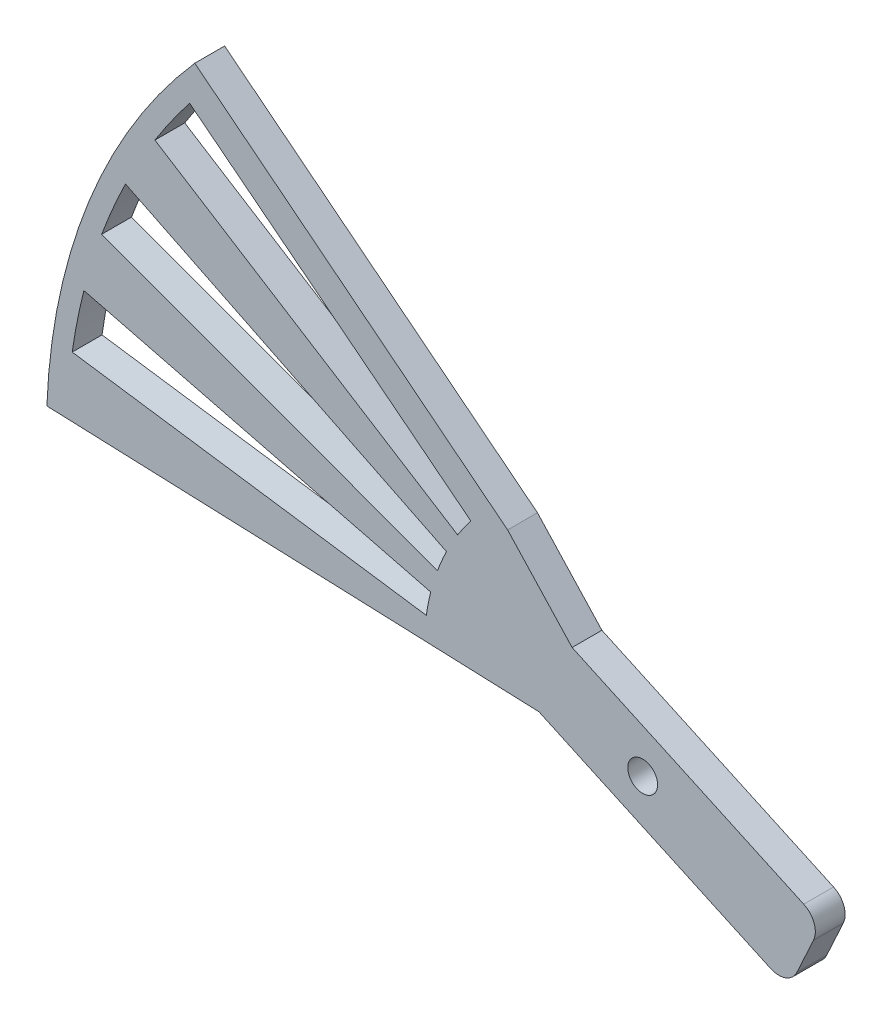
from build123d import *

# Parameters (mm, degrees)
BOSS_EXTRUDE2_DEPTH = 3
SKETCH1_8_R         = 1.5
BOSS_EXTRUDE5_DEPTH = 3
FILLET1_R           = 2
CUT_EXTRUDE1_REACH  = 73.918


with BuildPart() as part:
    # Sketch1 → Boss-Extrude2 (new body)
    with BuildSketch(Plane.XY):
        with BuildLine():
            Line((-19.985447982, 0.762803358), (-59.956343946, 2.288410074))
            ThreePointArc((-59.956343946, 2.288410074), (-55.730717245, 22.228071336), (-45.073672701, 39.602576043))
            Line((-45.073672701, 39.602576043), (-13.592462366, 14.67122922))
            ThreePointArc((-13.592462366, 14.67122922), (-18.172234131, 8.352838241), (-19.985447982, 0.762803358))
        make_face()
    extrude(amount=BOSS_EXTRUDE2_DEPTH)

    # Sketch1_8 → Boss-Extrude5 (add)
    with BuildSketch(Plane.XY):
        with BuildLine():
            ThreePointArc((-19.475648091, 4.549629811), (-19.821189154, 2.668419106), (-19.985447982, 0.762803358))
            Line((-19.985447982, 0.762803358), (-10.444898468, 0.398660247))
            Line((-10.444898468, 0.398660247), (14.68444307, -11.152001243))
            Line((14.68444307, -11.152001243), (18.025578366, -3.883107591))
            Line((18.025578366, -3.883107591), (-7.103763171, 7.667553899))
            Line((-7.103763171, 7.667553899), (-13.592462366, 14.67122922))
            ThreePointArc((-13.592462366, 14.67122922), (-14.931769674, 13.305722619), (-16.134512795, 11.818523464))
            ThreePointArc((-16.134512795, 11.818523464), (-18.172234131, 8.352838241), (-19.475648091, 4.549629811))
        make_face()
        Circle(SKETCH1_8_R, mode=Mode.SUBTRACT)
    extrude(amount=BOSS_EXTRUDE5_DEPTH)

    # Fillet1
    fillet1_edges = [part.edges().sort_by_distance(p)[0] for p in [
        (18.025578366, -3.883107591, 1.5),
        (14.68444307, -11.152001243, 1.5),
    ]]
    fillet(fillet1_edges, radius=FILLET1_R)

    # Sketch2 → Cut-Extrude1 (cut, up to next)
    with BuildSketch(Plane.XY.offset(3), mode=Mode.PRIVATE) as cut_extrude1_sk1:
        with BuildLine():
            Line((-52.047329922, 25.59444174), (-19.74209066, 9.708236522))
            ThreePointArc((-19.74209066, 9.708236522), (-20.223124653, 8.661710528), (-20.648728467, 7.591443388))
            Line((-20.648728467, 7.591443388), (-54.437556866, 20.013805296))
            ThreePointArc((-54.437556866, 20.013805296), (-53.315510448, 22.835418665), (-52.047329922, 25.59444174))
        make_face()
    cut_extrude1_tool1 = extrude(cut_extrude1_sk1.sketch, amount=-CUT_EXTRUDE1_REACH, mode=Mode.PRIVATE) & part.part
    # Sketch2 → Cut-Extrude1 (cut, up to next)
    with BuildSketch(Plane.XY.offset(3), mode=Mode.PRIVATE) as cut_extrude1_sk2:
        with BuildLine():
            Line((-56.231354546, 14.213893413), (-21.329134483, 5.391476812))
            ThreePointArc((-21.329134483, 5.391476812), (-21.58207174, 4.267807331), (-21.775854038, 3.132440087))
            Line((-21.775854038, 3.132440087), (-57.409069737, 8.25825114))
            ThreePointArc((-57.409069737, 8.25825114), (-56.898189132, 11.251492055), (-56.231354546, 14.213893413))
        make_face()
    cut_extrude1_tool2 = extrude(cut_extrude1_sk2.sketch, amount=-CUT_EXTRUDE1_REACH, mode=Mode.PRIVATE) & part.part
    # Sketch2 → Cut-Extrude1 (cut, up to next)
    with BuildSketch(Plane.XY.offset(3), mode=Mode.PRIVATE) as cut_extrude1_sk3:
        with BuildLine():
            Line((-49.08686154, 30.894660124), (-18.619154377, 11.718664185))
            ThreePointArc((-18.619154377, 11.718664185), (-17.980329977, 12.677055412), (-17.292222743, 13.600699711))
            Line((-17.292222743, 13.600699711), (-45.58858723, 35.856390146))
            ThreePointArc((-45.58858723, 35.856390146), (-47.402688122, 33.421327903), (-49.08686154, 30.894660124))
        make_face()
    cut_extrude1_tool3 = extrude(cut_extrude1_sk3.sketch, amount=-CUT_EXTRUDE1_REACH, mode=Mode.PRIVATE) & part.part
    add(cut_extrude1_tool1.solids().sort_by_distance((-39.233314, 16.803912, 3))[0], mode=Mode.SUBTRACT)
    add(cut_extrude1_tool2.solids().sort_by_distance((-41.869702, 8.279642, 3))[0], mode=Mode.SUBTRACT)
    add(cut_extrude1_tool3.solids().sort_by_distance((-34.882242, 24.593771, 3))[0], mode=Mode.SUBTRACT)


solid = part.part
